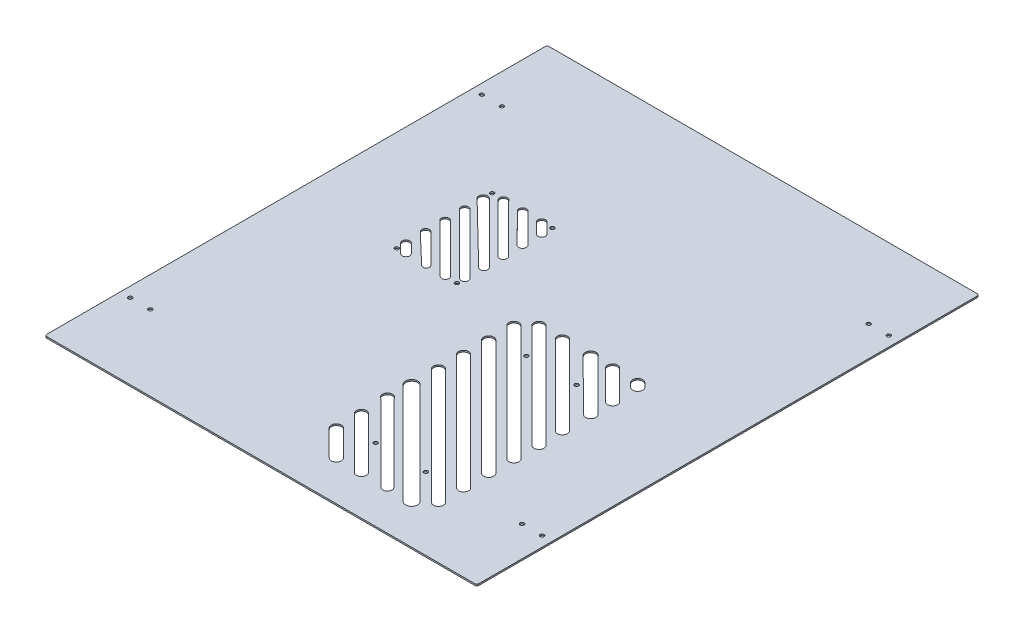
from build123d import *

# Parameters (mm, degrees)
SKETCH1_W           = 430
SKETCH1_H           = 500
BOSS_EXTRUDE1_DEPTH = 1.5
SKETCH12_R          = 1.95
CUT_EXTRUDE3_DEPTH  = 50.8
SKETCH6_R           = 1.95
CUT_EXTRUDE4_DEPTH  = 50.8
SKETCH7_R           = 1.95
CUT_EXTRUDE5_DEPTH  = 50.8
FILLET1_R           = 2
CUT_EXTRUDE6_DEPTH  = 10
SCALE1_SCALE        = 0.76


with BuildPart() as part:
    # Sketch1 → Boss-Extrude1 (new body)
    with BuildSketch(Plane(origin=(0, 0, 0), x_dir=(1, 0, 0), z_dir=(0, 1, 0))):
        Rectangle(SKETCH1_W, SKETCH1_H)
    extrude(amount=BOSS_EXTRUDE1_DEPTH)

    # Sketch12 → Cut-Extrude3 (cut)
    with BuildSketch(Plane(origin=(0, 0, 0), x_dir=(-1, 0, 0), z_dir=(0, -1, 0))):
        with Locations((-185, -175)):
            Circle(SKETCH12_R)
        with Locations((-205, 170)):
            Circle(SKETCH12_R)
        with Locations((-205, -175)):
            Circle(SKETCH12_R)
        with Locations((-185, 170)):
            Circle(SKETCH12_R)
        with Locations((205, -175)):
            Circle(SKETCH12_R)
        with Locations((185, 175)):
            Circle(SKETCH12_R)
        with Locations((205, 175)):
            Circle(SKETCH12_R)
        with Locations((185, -175)):
            Circle(SKETCH12_R)
    extrude(amount=-CUT_EXTRUDE3_DEPTH, mode=Mode.SUBTRACT)

    # Sketch6 → Cut-Extrude4 (cut)
    with BuildSketch(Plane(origin=(0, 1.5, 0), x_dir=(1, 0, 0), z_dir=(0, 1, 0))):
        with Locations((92.292697989, -28)):
            Circle(SKETCH6_R)
        with Locations((42.292697989, -28)):
            Circle(SKETCH6_R)
        with Locations((92.292697989, -178)):
            Circle(SKETCH6_R)
        with Locations((42.292697989, -178)):
            Circle(SKETCH6_R)
    extrude(amount=-CUT_EXTRUDE4_DEPTH, mode=Mode.SUBTRACT)

    # Sketch7 → Cut-Extrude5 (cut)
    with BuildSketch(Plane(origin=(0, 1.5, 0), x_dir=(1, 0, 0), z_dir=(0, 1, 0))):
        with Locations((-114.979961576, 95.192396061)):
            Circle(SKETCH7_R)
        with Locations((-54.979961576, 95.192396061)):
            Circle(SKETCH7_R)
        with Locations((-54.979961576, 0.192396061)):
            Circle(SKETCH7_R)
        with Locations((-114.979961576, 0.192396061)):
            Circle(SKETCH7_R)
    extrude(amount=-CUT_EXTRUDE5_DEPTH, mode=Mode.SUBTRACT)

    # Fillet1
    fillet1_edges = [part.edges().sort_by_distance(p)[0] for p in [
        (215, 0.75, 250),
        (-215, 0.75, 250),
        (-215, 0.75, -250),
        (215, 0.75, -250),
    ]]
    fillet(fillet1_edges, radius=FILLET1_R)

    # Sketch13 → Cut-Extrude6 (cut)
    with BuildSketch(Plane.XZ):
        with BuildLine():
            ThreePointArc((128.328231895, 194.409545443), (128.328231895, 201.480613255), (121.257164083, 201.480613255))
            Line((121.257164083, 201.480613255), (6.257164083, 86.480613255))
            ThreePointArc((6.257164083, 86.480613255), (6.257164083, 79.409545443), (13.328231895, 79.409545443))
            Line((13.328231895, 79.409545443), (128.328231895, 194.409545443))
        make_face()
        with BuildLine():
            ThreePointArc((114.891555161, 206.259007204), (114.891555161, 214.740992796), (106.409569569, 214.740992796))
            Line((106.409569569, 214.740992796), (5.551705193, 113.883128419))
            ThreePointArc((5.551705193, 113.883128419), (5.551705193, 105.401142828), (14.033690785, 105.401142828))
            Line((14.033690785, 105.401142828), (114.891555161, 206.259007204))
        make_face()
        with BuildLine():
            ThreePointArc((128.328231895, 169.409545443), (128.328231895, 176.480613255), (121.257164083, 176.480613255))
            Line((121.257164083, 176.480613255), (6.257164083, 61.480613255))
            ThreePointArc((6.257164083, 61.480613255), (6.257164083, 54.409545443), (13.328231895, 54.409545443))
            Line((13.328231895, 54.409545443), (128.328231895, 169.409545443))
        make_face()
        with BuildLine():
            ThreePointArc((128.328231895, 144.409545443), (128.328231895, 151.480613255), (121.257164083, 151.480613255))
            Line((121.257164083, 151.480613255), (6.257164083, 36.480613255))
            ThreePointArc((6.257164083, 36.480613255), (6.257164083, 29.409545443), (13.328231895, 29.409545443))
            Line((13.328231895, 29.409545443), (128.328231895, 144.409545443))
        make_face()
        with BuildLine():
            ThreePointArc((7.050771569, 137.384062043), (5.156114678, 129.125444121), (13.4147326, 131.020101013))
            Line((13.4147326, 131.020101013), (89.712651072, 207.318019485))
            ThreePointArc((89.712651072, 207.318019485), (89.712651072, 213.681980515), (83.348690041, 213.681980515))
            Line((83.348690041, 213.681980515), (7.050771569, 137.384062043))
        make_face()
        with BuildLine():
            ThreePointArc((128.328231895, 119.409545443), (128.328231895, 126.480613255), (121.257164083, 126.480613255))
            Line((121.257164083, 126.480613255), (6.257164083, 11.480613255))
            ThreePointArc((6.257164083, 11.480613255), (6.257164083, 4.409545443), (13.328231895, 4.409545443))
            Line((13.328231895, 4.409545443), (128.328231895, 119.409545443))
        make_face()
        with BuildLine():
            ThreePointArc((129.178407924, 95.256425689), (129.178407924, 102.327493501), (122.107340112, 102.327493501))
            Line((122.107340112, 102.327493501), (18.815380517, -0.964466094))
            ThreePointArc((18.815380517, -0.964466094), (18.815380517, -8.035533906), (25.886448329, -8.035533906))
            Line((25.886448329, -8.035533906), (129.178407924, 95.256425689))
        make_face()
        with BuildLine():
            ThreePointArc((64.186096271, 206.964466094), (64.186096271, 214.035533906), (57.115028459, 214.035533906))
            Line((57.115028459, 214.035533906), (6.257164083, 163.17766953))
            ThreePointArc((6.257164083, 163.17766953), (6.257164083, 156.106601718), (13.328231895, 156.106601718))
            Line((13.328231895, 156.106601718), (64.186096271, 206.964466094))
        make_face()
        with BuildLine():
            ThreePointArc((128.328231895, 71.106601718), (128.328231895, 78.17766953), (121.257164083, 78.17766953))
            Line((121.257164083, 78.17766953), (42.115028459, -0.964466094))
            ThreePointArc((42.115028459, -0.964466094), (42.115028459, -8.035533906), (49.186096271, -8.035533906))
            Line((49.186096271, -8.035533906), (128.328231895, 71.106601718))
        make_face()
        with BuildLine():
            ThreePointArc((128.434071453, 42.778300689), (128.450410182, 50.077386347), (121.151324524, 50.093725076))
            Line((121.151324524, 50.093725076), (70.101549086, -0.728014801))
            ThreePointArc((70.101549086, -0.728014801), (70.211536159, -8.378376983), (77.854021235, -8.014288369))
            Line((77.854021235, -8.014288369), (80.943634504, -4.5))
            Line((80.943634504, -4.5), (128.434071453, 42.778300689))
        make_face()
        with BuildLine():
            ThreePointArc((39.186096271, 206.964466094), (39.186090231, 214.035539946), (32.11501638, 214.035521827))
            Line((32.11501638, 214.035521827), (28.579518712, 210.5))
            Line((28.579518712, 210.5), (6.257188241, 188.17766953))
            ThreePointArc((6.257188241, 188.17766953), (6.257176162, 181.106613797), (13.328231895, 181.106601718))
            Line((13.328231895, 181.106601718), (39.186096271, 206.964466094))
        make_face()
        with BuildLine():
            ThreePointArc((128.328231895, 21.106601718), (128.328231895, 28.17766953), (121.257164083, 28.17766953))
            Line((121.257164083, 28.17766953), (92.115028459, -0.964466094))
            ThreePointArc((92.115028459, -0.964466094), (92.115028459, -8.035533906), (99.186096271, -8.035533906))
            Line((99.186096271, -8.035533906), (128.328231895, 21.106601718))
        make_face()
        with BuildLine():
            ThreePointArc((128.328449123, -3.893615534), (128.328449135, 3.177669518), (121.257164083, 3.17766953))
            Line((121.257164083, 3.17766953), (117.115028459, -0.964466094))
            ThreePointArc((117.115028459, -0.964466094), (117.11493575, -8.035441194), (124.185910844, -8.035719323))
            Line((124.185910844, -8.035719323), (128.328449123, -3.893615534))
        make_face()
        with BuildLine():
            Line((-60.282225947, -95.192396061), (-54.979961576, -89.89013169))
            Line((-54.979961576, -89.89013169), (-52.328312545, -87.235758493))
            ThreePointArc((-52.328312545, -87.235758493), (-52.33035331, -81.93586188), (-57.630250273, -81.936542135))
            Line((-57.630250273, -81.936542135), (-68.235815502, -92.542107364))
            ThreePointArc((-68.235815502, -92.542107364), (-68.236495757, -97.842004327), (-62.936599144, -97.844045092))
            Line((-62.936599144, -97.844045092), (-60.282225947, -95.192396061))
        make_face()
        with BuildLine():
            Line((-79.432380406, -95.192396061), (-52.328311176, -68.084345475))
            ThreePointArc((-52.328311176, -68.084345475), (-52.332091228, -62.778048343), (-57.638379198, -62.788609103))
            Line((-57.638379198, -62.788609103), (-87.242774375, -92.549084557))
            ThreePointArc((-87.242774375, -92.549084557), (-87.193524879, -97.884311066), (-81.85941362, -97.764626075))
            Line((-81.85941362, -97.764626075), (-79.432380406, -95.192396061))
        make_face()
        with BuildLine():
            Line((-98.589718565, -95.192396061), (-54.979961576, -51.582639071))
            Line((-54.979961576, -51.582639071), (-52.328311176, -48.930599166))
            ThreePointArc((-52.328311176, -48.930599166), (-52.332818712, -43.623576712), (-57.639827781, -43.636319812))
            Line((-57.639827781, -43.636319812), (-106.244222321, -92.550540935))
            ThreePointArc((-106.244222321, -92.550540935), (-106.146641992, -97.928953998), (-100.773557317, -97.670477564))
            Line((-100.773557317, -97.670477564), (-98.589718565, -95.192396061))
        make_face()
        with BuildLine():
            Line((-111.925519092, -89.374450278), (-52.328311147, -29.777242332))
            ThreePointArc((-52.328311147, -29.777242332), (-52.310450744, -24.491922995), (-57.595528665, -24.438342602))
            Line((-57.595528665, -24.438342602), (-117.992839573, -83.224558883))
            ThreePointArc((-117.992839573, -83.224558883), (-118.054977502, -89.353737319), (-111.925519092, -89.374450278))
        make_face()
        with BuildLine():
            Line((-112.328311147, -70.623496023), (-52.374195212, -10.669380088))
            ThreePointArc((-52.374195212, -10.669380088), (-52.374195212, -5.457847361), (-57.58572794, -5.457847361))
            Line((-57.58572794, -5.457847361), (-114.979961576, -62.668544735))
            Line((-114.979961576, -62.668544735), (-117.631612006, -65.320195164))
            ThreePointArc((-117.631612006, -65.320195164), (-117.631612006, -70.623496023), (-112.328311147, -70.623496023))
        make_face()
        with BuildLine():
            Line((-112.328311147, -51.123496023), (-63.949411742, -2.744596618))
            ThreePointArc((-63.949411742, -2.744596618), (-63.936748679, 2.34707829), (-69.028297614, 2.385067165))
            Line((-69.028297614, 2.385067165), (-71.657559216, -0.192396061))
            Line((-71.657559216, -0.192396061), (-114.979961576, -43.514798421))
            Line((-114.979961576, -43.514798421), (-117.432443337, -45.634975273))
            ThreePointArc((-117.432443337, -45.634975273), (-117.726028226, -51.025591461), (-112.328311147, -51.123496023))
        make_face()
        with BuildLine():
            Line((-112.328311147, -31.623496023), (-83.202607923, -2.497792799))
            ThreePointArc((-83.202607923, -2.497792799), (-83.175365618, 2.085432584), (-87.75794332, 2.167155652))
            Line((-87.75794332, 2.167155652), (-117.567824527, -26.25790651))
            ThreePointArc((-117.567824527, -26.25790651), (-117.662945906, -31.591787403), (-112.328311147, -31.623496023))
        make_face()
        with BuildLine():
            Line((-112.328311147, -12.123496023), (-103.048861614, -2.84404649))
            ThreePointArc((-103.048861614, -2.84404649), (-103.048861614, 2.459254369), (-108.352162473, 2.459254369))
            Line((-108.352162473, 2.459254369), (-117.631612006, -6.820195164))
            ThreePointArc((-117.631612006, -6.820195164), (-117.631612006, -12.123496023), (-112.328311147, -12.123496023))
        make_face()
    extrude(amount=-CUT_EXTRUDE6_DEPTH, mode=Mode.SUBTRACT)


with BuildPart() as part_1:
    # Scale1: scaled about (-3.718091903, 0.75, -7.04565373)
    add(part.part.scale(SCALE1_SCALE).moved(Location((-0.892342057, 0.18, -1.690956895))))


solid = part_1.part
